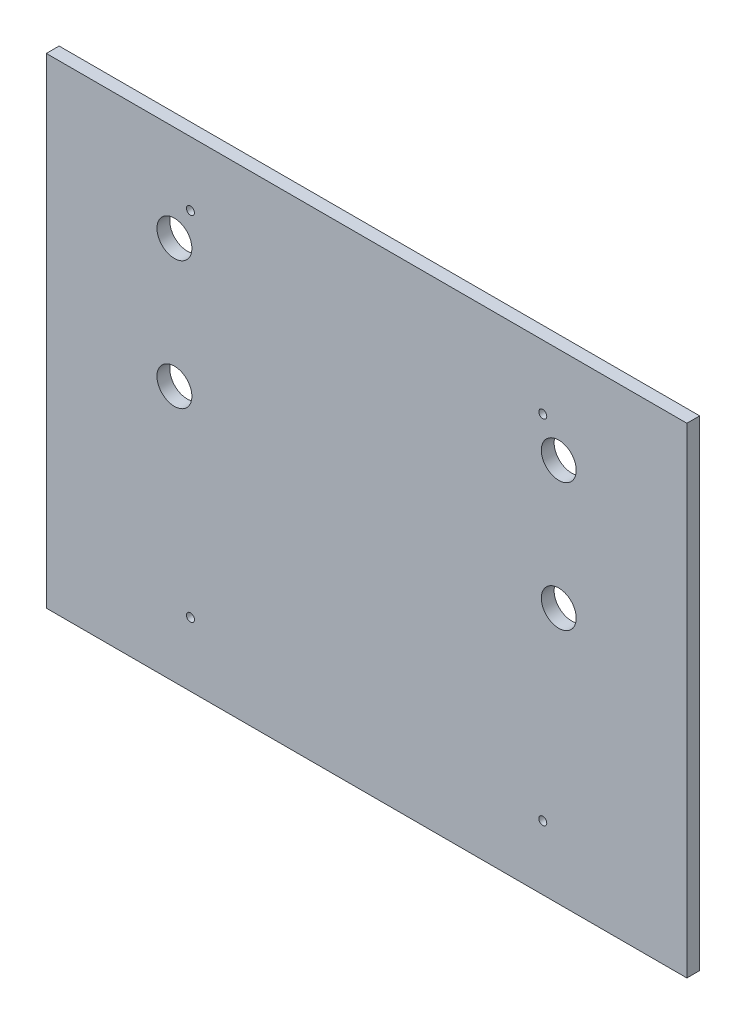
from build123d import *

# Parameters (mm, degrees)
SKETCH_1_W      = 400
SKETCH_1_H      = 300
SKETCH_1_R      = 10.9
SKETCH_1_R_2    = 2.5
EXTRUDE_1_DEPTH = 8


with BuildPart() as part:
    # 草图1 → 凸台-拉伸1 (new body)
    with BuildSketch(Plane.XY):
        with Locations((144.397869229, -115.797373506)):
            Rectangle(SKETCH_1_W, SKETCH_1_H)
        with Locations((24.397869229, -25.797373506)):
            Circle(SKETCH_1_R, mode=Mode.SUBTRACT)
        with Locations((264.397869229, -25.797373506)):
            Circle(SKETCH_1_R, mode=Mode.SUBTRACT)
        with Locations((254.397869229, -5.797373506)):
            Circle(SKETCH_1_R_2, mode=Mode.SUBTRACT)
        with Locations((34.397869229, -5.797373506)):
            Circle(SKETCH_1_R_2, mode=Mode.SUBTRACT)
        with Locations((34.397869229, -225.797373506)):
            Circle(SKETCH_1_R_2, mode=Mode.SUBTRACT)
        with Locations((254.397869229, -225.797373506)):
            Circle(SKETCH_1_R_2, mode=Mode.SUBTRACT)
        with Locations((24.397869229, -105.797373506)):
            Circle(SKETCH_1_R, mode=Mode.SUBTRACT)
        with Locations((264.397869229, -105.797373506)):
            Circle(SKETCH_1_R, mode=Mode.SUBTRACT)
    extrude(amount=EXTRUDE_1_DEPTH)


solid = part.part
